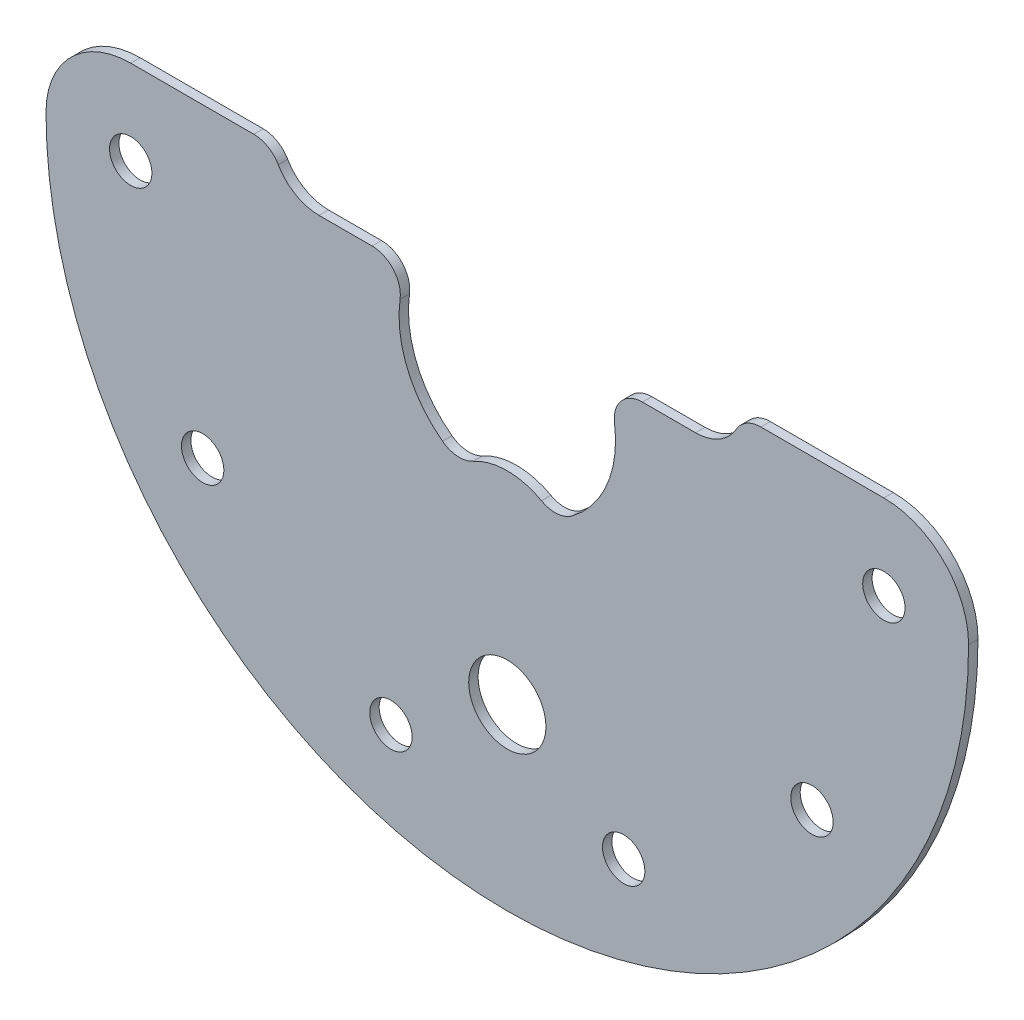
from build123d import *

# Parameters (mm, degrees)
SKETCH_1_R      = 2.25
SKETCH_1_R_2    = 4.1
EXTRUDE_1_DEPTH = 1


with BuildPart() as part:
    # 草图1 → 凸台-拉伸1 (new body)
    with BuildSketch(Plane.XY.offset(1)):
        with BuildLine():
            Line((-614.361406616, 5), (-620, 5))
            ThreePointArc((-620, 5), (-622.5, 5.669872981), (-624.330127019, 7.5))
            ThreePointArc((-624.330127019, 7.5), (-625.42820323, 8.598076211), (-626.92820323, 9))
            Line((-626.92820323, 9), (-640, 9))
            ThreePointArc((-640, 9), (-646.363961031, 6.363961031), (-649, 0))
            ThreePointArc((-649, 0), (-600, -49), (-551, 0))
            ThreePointArc((-551, 0), (-553.636038969, 6.363961031), (-560, 9))
            Line((-560, 9), (-573.07179677, 9))
            ThreePointArc((-573.07179677, 9), (-574.57179677, 8.598076211), (-575.669872981, 7.5))
            ThreePointArc((-575.669872981, 7.5), (-577.5, 5.669872981), (-580, 5))
            Line((-580, 5), (-585.638593384, 5))
            ThreePointArc((-585.638593384, 5), (-587.901487472, 3.969596493), (-588.60991889, 1.586206897))
            ThreePointArc((-588.60991889, 1.586206897), (-589.388591149, -4.432606704), (-593.122606779, -9.216911765))
            ThreePointArc((-593.122606779, -9.216911765), (-594.713337054, -9.80559868), (-596.369078113, -9.4375))
            ThreePointArc((-596.369078113, -9.4375), (-600, -8.5), (-603.630921887, -9.4375))
            ThreePointArc((-603.630921887, -9.4375), (-605.286662946, -9.80559868), (-606.877393221, -9.216911765))
            ThreePointArc((-606.877393221, -9.216911765), (-610.611408851, -4.432606704), (-611.39008111, 1.586206897))
            ThreePointArc((-611.39008111, 1.586206897), (-612.098512528, 3.969596493), (-614.361406616, 5))
        make_face()
        with Locations((-640, 0)):
            Circle(SKETCH_1_R, mode=Mode.SUBTRACT)
        with Locations((-600, -30)):
            Circle(SKETCH_1_R_2, mode=Mode.SUBTRACT)
        with Locations((-567.639320225, -23.511410092)):
            Circle(SKETCH_1_R, mode=Mode.SUBTRACT)
        with Locations((-587.639320225, -38.042260652)):
            Circle(SKETCH_1_R, mode=Mode.SUBTRACT)
        with Locations((-612.360679775, -38.042260652)):
            Circle(SKETCH_1_R, mode=Mode.SUBTRACT)
        with Locations((-632.360679775, -23.511410092)):
            Circle(SKETCH_1_R, mode=Mode.SUBTRACT)
        with Locations((-560, 0)):
            Circle(SKETCH_1_R, mode=Mode.SUBTRACT)
    extrude(amount=-EXTRUDE_1_DEPTH)


solid = part.part
